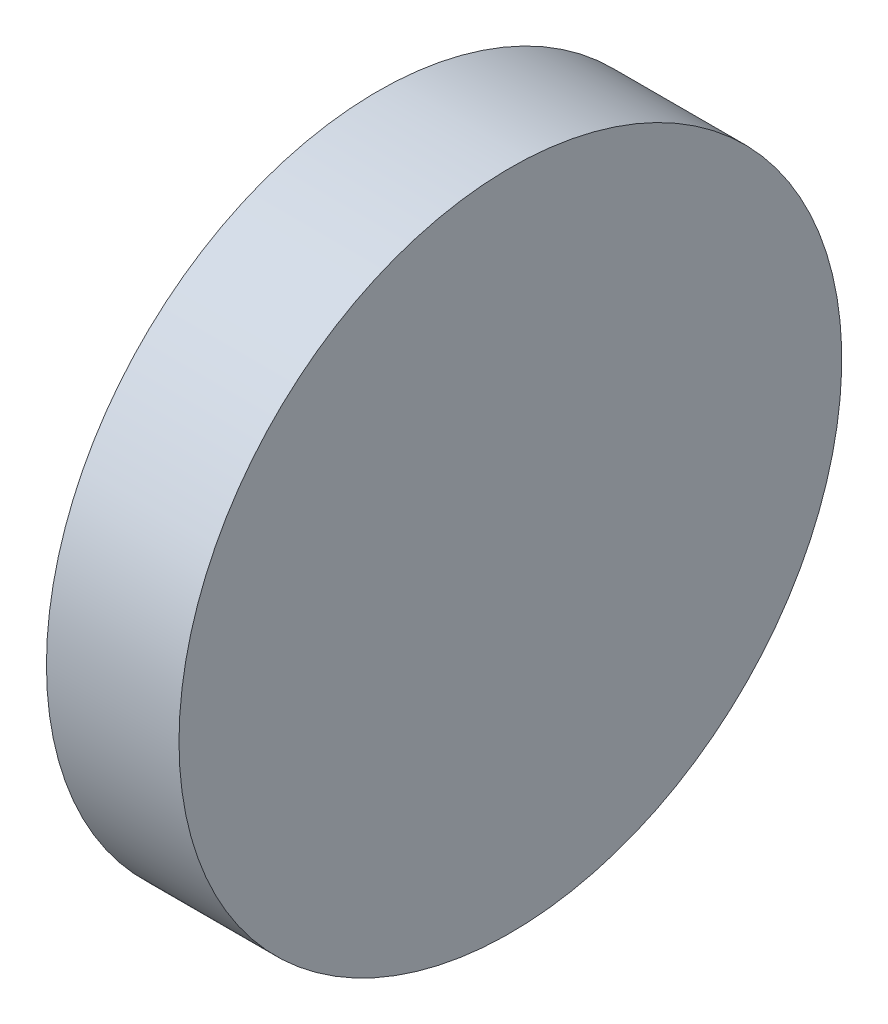
from build123d import *

# Parameters (mm, degrees)
SKETCH_1_W = 6
SKETCH_1_H = 15


with BuildPart() as part:
    # 草图1 → 旋转1 (revolve)
    with BuildSketch(Plane.XY, mode=Mode.PRIVATE) as revolve_1_sk:
        with Locations((259.884904083, 84.811360012)):
            Rectangle(SKETCH_1_W, SKETCH_1_H)
    revolve(revolve_1_sk.sketch.rotate(Axis((251.374901691, 77.311360012, 0), (1, 0, 0)), 90), axis=Axis((251.374901691, 77.311360012, 0), (1, 0, 0)))  # turned: the seam where the file's is


solid = part.part
